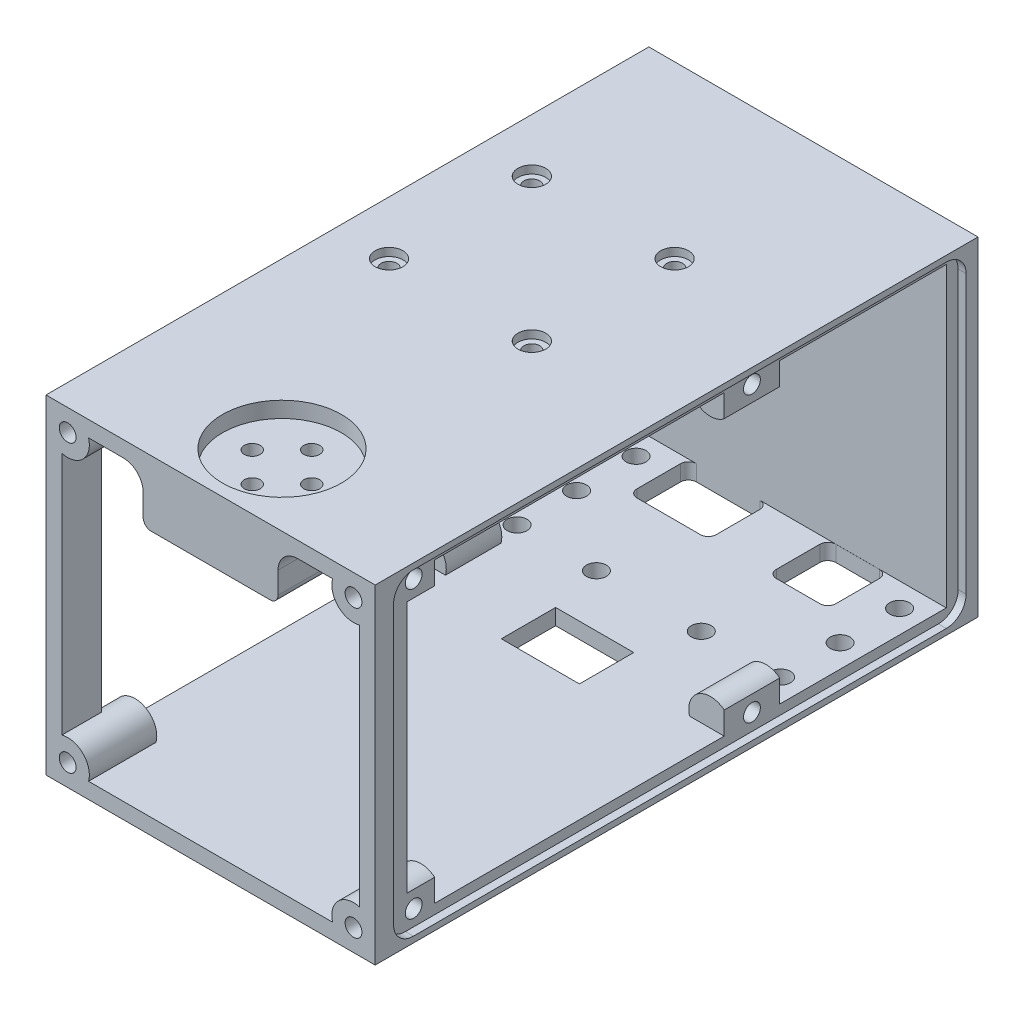
from build123d import *
from build123d.topology import SkipClean

# Parameters (mm, degrees)
SKETCH1_W           = 83
SKETCH1_H           = 83
SKETCH1_W_2         = 75
SKETCH1_H_2         = 75
BOSS_EXTRUDE1_DEPTH = 150
SKETCH2_W           = 83
SKETCH2_H           = 83
BOSS_EXTRUDE2_DEPTH = 4
SKETCH3_R           = 5.464466094
BOSS_EXTRUDE3_DEPTH = 10
SKETCH4_R           = 2.125
CUT_EXTRUDE1_DEPTH  = 4
CUT_EXTRUDE3_DEPTH  = 177.38381496
BOSS_EXTRUDE4_DEPTH = 40
SKETCH10_R          = 2.5
SKETCH10_W          = 19.7
SKETCH10_H          = 13.7
CUT_EXTRUDE4_DEPTH  = 24
SKETCH11_R          = 2
CUT_EXTRUDE5_DEPTH  = 24
SKETCH11_3_R        = 3.5
SKETCH11_3_R_2      = 2
CUT_EXTRUDE6_DEPTH  = 2
SKETCH12_R          = 2
CUT_EXTRUDE7_DEPTH  = 170.246861655
SKETCH13_R          = 15
CUT_EXTRUDE8_DEPTH  = 4
SKETCH15_W          = 83
SKETCH15_H          = 83
BOSS_EXTRUDE5_DEPTH = 2
CUT_EXTRUDE9_DEPTH  = 2
BOSS_EXTRUDE6_DEPTH = 7
SKETCH17_R          = 2.125
CUT_EXTRUDE10_DEPTH = 4
BOSS_EXTRUDE7_DEPTH = 14
SKETCH19_R          = 2.125
CUT_EXTRUDE11_DEPTH = 4
SKETCH20_R          = 2.125
CUT_EXTRUDE12_DEPTH = 4


with BuildPart() as part:
    # Sketch1 → Boss-Extrude1 (new body)
    with BuildSketch(Plane(origin=(0, 0, 0), x_dir=(0, 1, 0), z_dir=(0, 0, 1))):
        Rectangle(SKETCH1_W, SKETCH1_H)
        Rectangle(SKETCH1_W_2, SKETCH1_H_2, mode=Mode.SUBTRACT)
    extrude(amount=BOSS_EXTRUDE1_DEPTH)

    # Sketch2 → Boss-Extrude2 (add)
    with BuildSketch(Plane(origin=(0, 0, 0), x_dir=(1, 0, 0), z_dir=(0, 0, -1))):
        Rectangle(SKETCH2_W, SKETCH2_H)
    extrude(amount=-BOSS_EXTRUDE2_DEPTH)

    # Sketch3 → Boss-Extrude3 (add)
    with BuildSketch(Plane.XY.offset(150)):
        with Locations((-36.035533906, 36.035533906)):
            Circle(SKETCH3_R)
        with Locations((36.035533906, 36.035533906)):
            Circle(SKETCH3_R)
        with Locations((36.035533906, -36.035533906)):
            Circle(SKETCH3_R)
        with Locations((-36.035533906, -36.035533906)):
            Circle(SKETCH3_R)
    extrude(amount=-BOSS_EXTRUDE3_DEPTH)

    # Sketch4 → Cut-Extrude1 (cut)
    with BuildSketch(Plane.XY.offset(150)):
        with Locations((-36.035533906, 36.035533906)):
            Circle(SKETCH4_R)
        with Locations((36.035533921, 36.035493754)):
            Circle(SKETCH4_R)
        with Locations((36.035493769, -36.035574073)):
            Circle(SKETCH4_R)
        with Locations((-36.035574057, -36.035533921)):
            Circle(SKETCH4_R)
    extrude(amount=-CUT_EXTRUDE1_DEPTH, mode=Mode.SUBTRACT)

    # Sketch6 → Cut-Extrude3 (cut, through all)
    with BuildSketch(Plane(origin=(-41.5, 0, 0), x_dir=(0, -1, 0), z_dir=(-1, 0, 0))):
        with BuildLine():
            Line((37.5, 4), (-37.5, 4))
            Line((-37.5, 4), (-37.5, 136.585279453))
            ThreePointArc((-37.5, 136.585279453), (-36.499851508, 138.999851508), (-34.085279453, 140))
            Line((-34.085279453, 140), (34.085279453, 140))
            ThreePointArc((34.085279453, 140), (36.499851508, 138.999851508), (37.5, 136.585279453))
            Line((37.5, 136.585279453), (37.5, 4))
        make_face()
    extrude(amount=-CUT_EXTRUDE3_DEPTH, mode=Mode.SUBTRACT)

    # Sketch9 → Boss-Extrude4 (add)
    with BuildSketch(Plane.XY.offset(150)):
        with BuildLine():
            Line((15, 25), (-15, 25))
            ThreePointArc((-15, 25), (-16.414213562, 25.585786438), (-17, 27))
            Line((-17, 27), (-17, 32.5))
            ThreePointArc((-17, 32.5), (-18.464466094, 36.035533906), (-22, 37.5))
            Line((-22, 37.5), (22, 37.5))
            ThreePointArc((22, 37.5), (18.464466094, 36.035533906), (17, 32.5))
            Line((17, 32.5), (17, 27))
            ThreePointArc((17, 27), (16.414213562, 25.585786438), (15, 25))
        make_face()
    extrude(amount=-BOSS_EXTRUDE4_DEPTH)

    # Sketch10 → Cut-Extrude4 (cut)
    with BuildSketch(Plane.XZ.offset(41.5)):
        with Locations((33.72267018, 40)):
            Circle(SKETCH10_R)
        with Locations((33.72267018, 25)):
            Circle(SKETCH10_R)
        with Locations((33.72267018, 10)):
            Circle(SKETCH10_R)
        with Locations((-32.71848924, 40)):
            Circle(SKETCH10_R)
        with Locations((-32.71848924, 10)):
            Circle(SKETCH10_R)
        with Locations((-32.71848924, 25)):
            Circle(SKETCH10_R)
        with Locations((-12.71848924, 40)):
            Circle(SKETCH10_R)
        with Locations((13.72267018, 40)):
            Circle(SKETCH10_R)
        with BuildLine():
            Line((-23.5, 4), (-7.5, 4))
            ThreePointArc((-7.5, 4), (-6.085786438, 4.585786438), (-5.5, 6))
            Line((-5.5, 6), (-5.5, 17))
            ThreePointArc((-5.5, 17), (-6.085786438, 18.414213562), (-7.5, 19))
            Line((-7.5, 19), (-23.5, 19))
            ThreePointArc((-23.5, 19), (-24.914213562, 18.414213562), (-25.5, 17))
            Line((-25.5, 17), (-25.5, 6))
            ThreePointArc((-25.5, 6), (-24.914213562, 4.585786438), (-23.5, 4))
        make_face()
        with BuildLine():
            Line((9.661835749, 6.015151515), (9.661835749, 17.015151515))
            ThreePointArc((9.661835749, 17.015151515), (10.247622186, 18.429365078), (11.661835749, 19.015151515))
            Line((11.661835749, 19.015151515), (22.661835749, 19.015151515))
            ThreePointArc((22.661835749, 19.015151515), (24.076049311, 18.429365078), (24.661835749, 17.015151515))
            Line((24.661835749, 17.015151515), (24.661835749, 6.015151515))
            ThreePointArc((24.661835749, 6.015151515), (24.076049311, 4.600937953), (22.661835749, 4.015151515))
            Line((22.661835749, 4.015151515), (11.661835749, 4.015151515))
            ThreePointArc((11.661835749, 4.015151515), (10.247622186, 4.600937953), (9.661835749, 6.015151515))
        make_face()
        with Locations((0, 60)):
            Rectangle(SKETCH10_W, SKETCH10_H)
    extrude(amount=-CUT_EXTRUDE4_DEPTH, mode=Mode.SUBTRACT)

    # Sketch11 → Cut-Extrude5 (cut)
    with BuildSketch(Plane(origin=(0, 41.5, 0), x_dir=(-1, 0, 0), z_dir=(0, 1, 0))):
        with Locations((-8, 76.99974406)):
            Circle(SKETCH11_R)
        with Locations((28, 76.99974406)):
            Circle(SKETCH11_R)
        with Locations((-8, 40.99974406)):
            Circle(SKETCH11_R)
        with Locations((28, 40.99974406)):
            Circle(SKETCH11_R)
    extrude(amount=-CUT_EXTRUDE5_DEPTH, mode=Mode.SUBTRACT)

    # Sketch11_3 → Cut-Extrude6 (cut)
    # profile 1 of 4: a face of its own
    with BuildSketch(Plane(origin=(0, 41.5, 0), x_dir=(-1, 0, 0), z_dir=(0, 1, 0))):
        with Locations((-8, 76.99974406)):
            Circle(SKETCH11_3_R)
        with Locations((-8, 76.99974406)):
            Circle(SKETCH11_3_R_2, mode=Mode.SUBTRACT)
    # profile 2 of 4: a face of its own
    with BuildSketch(Plane(origin=(0, 41.5, 0), x_dir=(-1, 0, 0), z_dir=(0, 1, 0))):
        with Locations((28, 76.99974406)):
            Circle(SKETCH11_3_R)
        with Locations((28, 76.99974406)):
            Circle(SKETCH11_3_R_2, mode=Mode.SUBTRACT)
    # profile 3 of 4: a face of its own
    with BuildSketch(Plane(origin=(0, 41.5, 0), x_dir=(-1, 0, 0), z_dir=(0, 1, 0))):
        with Locations((-8, 40.99974406)):
            Circle(SKETCH11_3_R)
        with Locations((-8, 40.99974406)):
            Circle(SKETCH11_3_R_2, mode=Mode.SUBTRACT)
    # profile 4 of 4: a face of its own
    with BuildSketch(Plane(origin=(0, 41.5, 0), x_dir=(-1, 0, 0), z_dir=(0, 1, 0))):
        with Locations((28, 40.99974406)):
            Circle(SKETCH11_3_R)
        with Locations((28, 40.99974406)):
            Circle(SKETCH11_3_R_2, mode=Mode.SUBTRACT)
    extrude(amount=-CUT_EXTRUDE6_DEPTH, mode=Mode.SUBTRACT)

    # Sketch12 → Cut-Extrude7 (cut, through all)
    with BuildSketch(Plane.XZ.offset(-25)):
        with Locations((0, 139.5)):
            Circle(SKETCH12_R)
        with Locations((-7.5, 132)):
            Circle(SKETCH12_R)
        with Locations((0, 124.5)):
            Circle(SKETCH12_R)
        with Locations((7.5, 132)):
            Circle(SKETCH12_R)
    extrude(amount=-CUT_EXTRUDE7_DEPTH, mode=Mode.SUBTRACT)

    # Sketch13 → Cut-Extrude8 (cut)
    with BuildSketch(Plane(origin=(0, 41.5, 0), x_dir=(-1, 0, 0), z_dir=(0, 1, 0))):
        with Locations((0, 132)):
            Circle(SKETCH13_R)
    extrude(amount=-CUT_EXTRUDE8_DEPTH, mode=Mode.SUBTRACT)

    # Sketch15 → Boss-Extrude5 (add)
    with BuildSketch(Plane(origin=(0, 0, 0), x_dir=(1, 0, 0), z_dir=(0, 0, -1))):
        Rectangle(SKETCH15_W, SKETCH15_H)
    extrude(amount=BOSS_EXTRUDE5_DEPTH)

    # Sketch14 → Cut-Extrude9 (cut)
    with BuildSketch(Plane(origin=(-41.5, 0, 0), x_dir=(0, -1, 0), z_dir=(-1, 0, 0))):
        with BuildLine():
            Line((-35, 1), (35, 1))
            ThreePointArc((35, 1), (38.535533906, 2.464466094), (40, 6))
            Line((40, 6), (40, 140.363661278))
            ThreePointArc((40, 140.363661278), (38.535533906, 143.899195184), (35, 145.363661278))
            Line((35, 145.363661278), (-35, 145.363661278))
            ThreePointArc((-35, 145.363661278), (-38.535533906, 143.899195184), (-40, 140.363661278))
            Line((-40, 140.363661278), (-40, 6))
            ThreePointArc((-40, 6), (-38.535533906, 2.464466094), (-35, 1))
        make_face()
    cut_extrude9 = extrude(amount=-CUT_EXTRUDE9_DEPTH, mode=Mode.SUBTRACT)

    # Mirror1: Cut-Extrude9 across plane
    add(cut_extrude9.mirror(Plane(origin=(0, 0, 0), x_dir=(0, 0, 1), z_dir=(1, 0, 0))), mode=Mode.SUBTRACT)

    # Sketch16 → Boss-Extrude6 (add)
    with SkipClean():  # the faces are left unmerged after this step: merging them gives an invalid solid
        with BuildSketch(Plane(origin=(0, 0, 140), x_dir=(1, 0, 0), z_dir=(0, 0, -1))):
            with BuildLine():
                Line((39.5, -37.5), (30.770960917, -37.5))
                ThreePointArc((30.770960917, -37.5), (33.051402638, -31.457832488), (39.5, -31.809677262))
                Line((39.5, -31.809677262), (39.5, -37.5))
            make_face()
            with BuildLine():
                Line((-39.5, 37.5), (-30.770960917, 37.5))
                ThreePointArc((-30.770960917, 37.5), (-33.051402638, 31.457832488), (-39.5, 31.809677262))
                Line((-39.5, 31.809677262), (-39.5, 37.5))
            make_face()
            with BuildLine():
                Line((-39.5, -31.809677262), (-39.5, -37.5))
                Line((-39.5, -37.5), (-30.770960917, -37.5))
                ThreePointArc((-30.770960917, -37.5), (-33.051402638, -31.457832488), (-39.5, -31.809677262))
            make_face()
            with BuildLine():
                Line((39.5, 31.809677262), (39.5, 37.5))
                Line((39.5, 37.5), (30.770960917, 37.5))
                ThreePointArc((30.770960917, 37.5), (33.051402638, 31.457832488), (39.5, 31.809677262))
            make_face()
        extrude(amount=BOSS_EXTRUDE6_DEPTH)

    # Sketch17 → Cut-Extrude10 (cut)
    with SkipClean():  # the faces are left unmerged after this step: merging them gives an invalid solid
        with BuildSketch(Plane.YZ.offset(39.5)):
            with Locations((36, 138.285341489)):
                Circle(SKETCH17_R)
            with Locations((-36, 138.285341489)):
                Circle(SKETCH17_R)
        cut_extrude10 = extrude(amount=-CUT_EXTRUDE10_DEPTH, mode=Mode.SUBTRACT)

    # Mirror2: Cut-Extrude10 across plane
    with SkipClean():  # the faces are left unmerged after this step: merging them gives an invalid solid
        add(cut_extrude10.mirror(Plane(origin=(0, 0, 0), x_dir=(0, 0, 1), z_dir=(1, 0, 0))), mode=Mode.SUBTRACT)

    # Sketch18 → Boss-Extrude7 (add)
    with SkipClean():  # the faces are left unmerged after this step: merging them gives an invalid solid
        with BuildSketch(Plane.XY.offset(60)):
            with BuildLine():
                Line((30.770960917, -37.5), (39.5, -37.5))
                Line((39.5, -37.5), (39.5, -31.809677262))
                ThreePointArc((39.5, -31.809677262), (33.051402638, -31.457832488), (30.770960917, -37.5))
            make_face()
            with BuildLine():
                Line((-30.770960917, 37.5), (-39.5, 37.5))
                Line((-39.5, 37.5), (-39.5, 31.809677262))
                ThreePointArc((-39.5, 31.809677262), (-33.051402638, 31.457832488), (-30.770960917, 37.5))
            make_face()
            with BuildLine():
                ThreePointArc((-30.770960917, -37.5), (-33.051402638, -31.457832488), (-39.5, -31.809677262))
                Line((-39.5, -31.809677262), (-39.5, -37.5))
                Line((-39.5, -37.5), (-30.770960917, -37.5))
            make_face()
            with BuildLine():
                ThreePointArc((30.770960917, 37.5), (33.051402638, 31.457832488), (39.5, 31.809677262))
                Line((39.5, 31.809677262), (39.5, 37.5))
                Line((39.5, 37.5), (30.770960917, 37.5))
            make_face()
        extrude(amount=-BOSS_EXTRUDE7_DEPTH)

    # Sketch19 → Cut-Extrude11 (cut)
    with SkipClean():  # the faces are left unmerged after this step: merging them gives an invalid solid
        with BuildSketch(Plane(origin=(-39.5, 0, 0), x_dir=(0, -1, 0), z_dir=(-1, 0, 0))):
            with Locations((35.809677262, 53)):
                Circle(SKETCH19_R)
        cut_extrude11 = extrude(amount=-CUT_EXTRUDE11_DEPTH, mode=Mode.SUBTRACT)

    # Sketch20 → Cut-Extrude12 (cut)
    with SkipClean():  # the faces are left unmerged after this step: merging them gives an invalid solid
        with BuildSketch(Plane.YZ.offset(39.5)):
            with Locations((35.809677262, 53)):
                Circle(SKETCH20_R)
        cut_extrude12 = extrude(amount=-CUT_EXTRUDE12_DEPTH, mode=Mode.SUBTRACT)

    # Mirror3: Cut-Extrude11 across plane
    with SkipClean():  # the faces are left unmerged after this step: merging them gives an invalid solid
        add(cut_extrude11.mirror(Plane(origin=(0, 0, 0), x_dir=(0, 0, 1), z_dir=(1, 0, 0))), mode=Mode.SUBTRACT)

    # Mirror4: Cut-Extrude12 across plane
    with SkipClean():  # the faces are left unmerged after this step: merging them gives an invalid solid
        add(cut_extrude12.mirror(Plane(origin=(0, 0, 0), x_dir=(0, 0, 1), z_dir=(1, 0, 0))), mode=Mode.SUBTRACT)


solid = part.part
